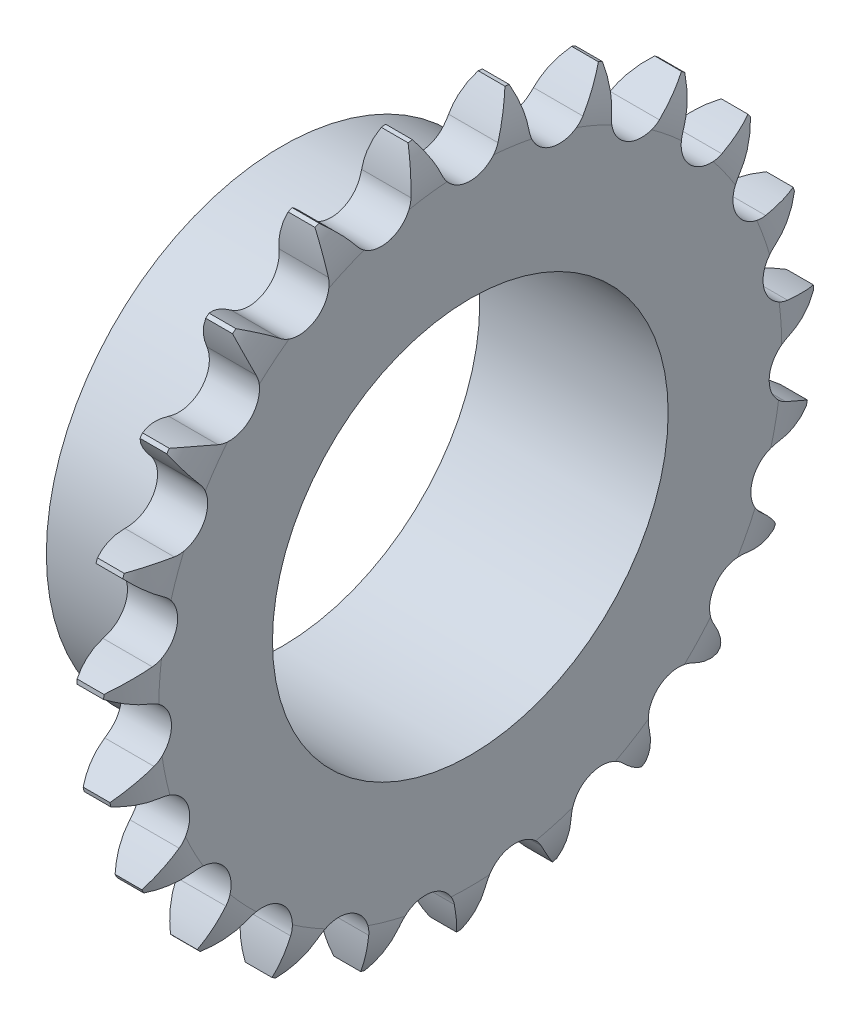
from build123d import *

# Parameters (mm, degrees)
TOOTHCUT_DEPTH     = 6.3196
TEETHCUTS_COUNT    = 23
TEETHCUTS_ANGLE    = 344.347826087
HUBNEAONESKE_R     = 25
HUBNEARONE_DEPTH   = 14.6809
HUBNEARONEFILLET_R = 0.4
BORSKE_R           = 21
BORE_DEPTH         = 20.0005


with BuildPart() as part:
    # BasProSke → Base-Revolve (revolve)
    with BuildSketch(Plane(origin=(0, 0, 0), x_dir=(1, 0, 0), z_dir=(0, 1, 0))):
        with BuildLine():
            Line((0, 0), (0, 33.05777326))
            ThreePointArc((0, 33.05777326), (0.314698702, 35.485936145), (1.238, 37.753649749))
            Line((1.238, 37.753649749), (4.0816, 37.753649749))
            ThreePointArc((4.0816, 37.753649749), (5.004901298, 35.485936145), (5.3196, 33.05777326))
            Line((5.3196, 33.05777326), (5.3196, 0))
            Line((5.3196, 0), (0, 0))
        make_face()
    revolve(axis=Axis((-10, 0, 0), (1, 0, 0)))

    # TooCutSke → ToothCut (cut, through all)
    with BuildSketch(Plane(origin=(0, 0, 0), x_dir=(0, 0, -1), z_dir=(1, 0, 0))):
        with BuildLine():
            ThreePointArc((2.97415754, 33.808261616), (3.980578959, 35.920428815), (5.23833278, 37.893292134))
            ThreePointArc((5.23833278, 37.893292134), (0, 38.253649749), (-5.23833278, 37.893292134))
            ThreePointArc((-5.23833278, 37.893292134), (-3.980578959, 35.920428815), (-2.97415754, 33.808261616))
            ThreePointArc((-2.97415754, 33.808261616), (0, 31.800524749), (2.97415754, 33.808261616))
        make_face()
    toothcut = extrude(amount=TOOTHCUT_DEPTH, mode=Mode.SUBTRACT)

    # TeethCuts: ToothCut ×23 about axis
    teethcuts_axis = Axis((-10, 0, 0), (1, 0, 0))
    for i in range(1, TEETHCUTS_COUNT):
        add(toothcut.rotate(teethcuts_axis, i * TEETHCUTS_ANGLE / (TEETHCUTS_COUNT - 1)), mode=Mode.SUBTRACT)

    # HubNeaOneSke → HubNearOne (add)
    with BuildSketch(Plane.ZY):
        Circle(HUBNEAONESKE_R)
    extrude(amount=HUBNEARONE_DEPTH)

    # HubNearOneFillet
    hubnearonefillet_edges = [part.edges().sort_by_distance(p)[0] for p in [
        (0, 0, -25),
    ]]
    fillet(hubnearonefillet_edges, radius=HUBNEARONEFILLET_R)

    # BorSke → Bore (cut, symmetric)
    with BuildSketch(Plane(origin=(0, 0, 0), x_dir=(0, 0, -1), z_dir=(1, 0, 0))):
        Circle(BORSKE_R)
    extrude(amount=BORE_DEPTH, both=True, mode=Mode.SUBTRACT)


solid = part.part
